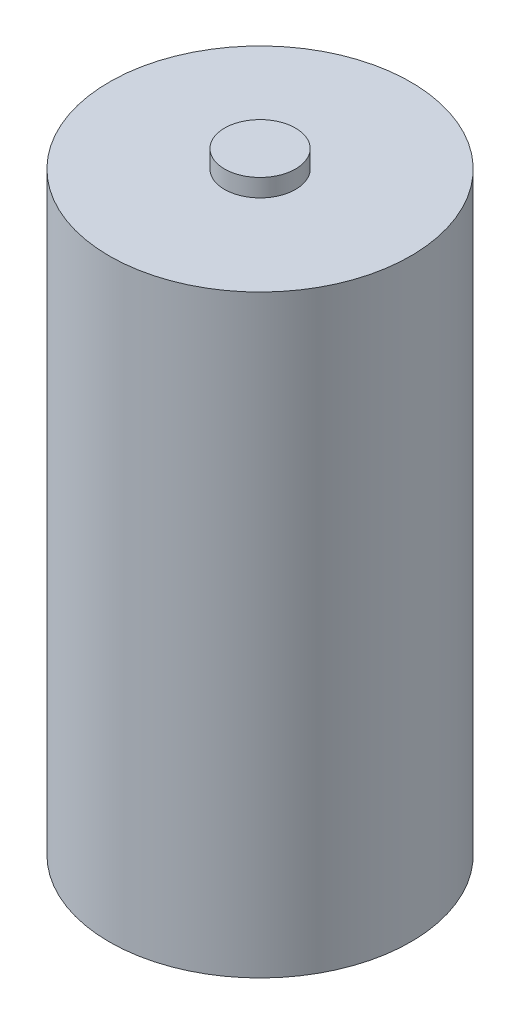
from build123d import *


with BuildPart() as part:
    # Sketch1 → Revolve1 (revolve)
    with BuildSketch(Plane.XY):
        Polygon((0, 0), (-8.5, 0), (-8.5, 33.5), (-2, 33.5), (-2, 34.5), (0, 34.5), align=None)
    revolve(axis=Axis((0, 34.5, 0), (0, -1, 0)))


solid = part.part
